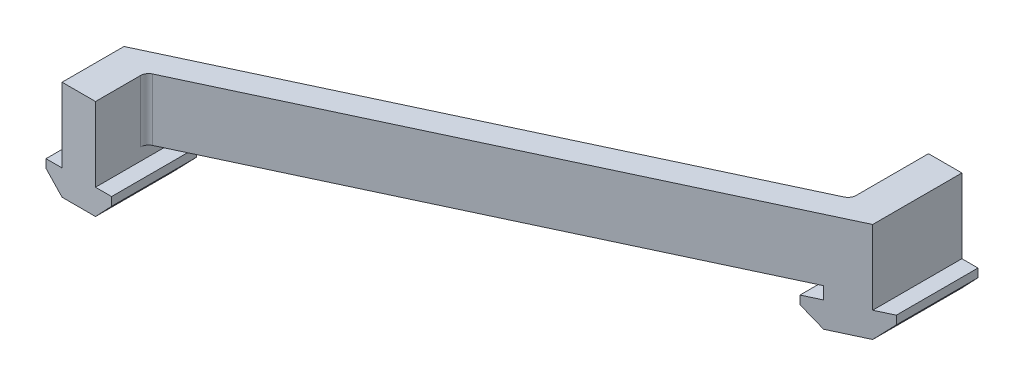
from build123d import *

# Parameters (mm, degrees)
BOSS_EXTRUDE1_DEPTH = 60
CUT_EXTRUDE2_DEPTH  = 25.152414984
BOSS_EXTRUDE2_DEPTH = 15
CUT_EXTRUDE3_DEPTH  = 25.152414984
BOSS_EXTRUDE3_DEPTH = 15
BOSS_EXTRUDE4_DEPTH = 15
CUT_EXTRUDE4_DEPTH  = 25.152414984
FILLET1_R           = 2


with BuildPart() as part:
    # Sketch1 → Boss-Extrude1 (new body)
    with BuildSketch(Plane.XY):
        Polygon((4.05, 18), (-124.05, 18), (-124.05, 0), (-115.95, 0), (-115.95, 3), (-4.05, 3), (-4.05, 0), (-7.95, 0), (-7.95, -2.04), (-4.048, -6.152414984), (4.048, -6.152414984), (7.95, -2.04), (7.95, 0), (4.05, 0), align=None)
    extrude(amount=BOSS_EXTRUDE1_DEPTH)

    # Sketch2 → Cut-Extrude2 (cut, through all)
    with BuildSketch(Plane(origin=(0, 18, 0), x_dir=(1, 0, 0), z_dir=(0, 1, 0))):
        Polygon((4.05, -60), (4.05, -6.625542325), (-109.904467136, -60), align=None)
        Polygon((-124.05, -60), (4.05, 0), (-124.05, 0), align=None)
        Polygon((11.122904285, -3.312706594), (4.05, -6.625542325), (4.05, -60), (-109.904467136, -60), (-126.032958173, -67.554328354), (-83.616740574, -158.112952928), (53.539121883, -93.871331168), align=None)
    extrude(amount=-CUT_EXTRUDE2_DEPTH, mode=Mode.SUBTRACT)

    # Sketch3 → Boss-Extrude2 (add, symmetric)
    with BuildSketch(Plane.XY.offset(60)):
        Polygon((-124.05, 18), (-124.05, 0), (-127.95, 0), (-127.95, -2.04), (-124.048, -6.152414984), (-115.952, -6.152414984), (-112.05, -2.04), (-112.05, 0), (-115.95, 0), (-115.95, 3), (-115.95, 18), align=None)
    extrude(amount=BOSS_EXTRUDE2_DEPTH, both=True)

    # Sketch2_4 → Cut-Extrude3 (cut, through all)
    with BuildSketch(Plane(origin=(0, 18, 0), x_dir=(1, 0, 0), z_dir=(0, 1, 0))):
        Polygon((4.05, 0), (-128.577931229, -62.12081088), (-170.994148827, 28.437813693), (-38.366217599, 90.558624573), align=None)
    extrude(amount=-CUT_EXTRUDE3_DEPTH, mode=Mode.SUBTRACT)

    # Sketch4 → Boss-Extrude3 (add)
    with BuildSketch(Plane(origin=(0, 18, 0), x_dir=(1, 0, 0), z_dir=(0, 1, 0))):
        Polygon((-109.904467136, -60), (-115.95, -62.831631318), (-115.95, -60), align=None)
    extrude(amount=-BOSS_EXTRUDE3_DEPTH)

    # Sketch6 → Boss-Extrude4 (add, symmetric)
    with BuildSketch(Plane(origin=(0, 0, 0), x_dir=(-1, 0, 0), z_dir=(0, 0, -1))):
        Polygon((-4.05, 0), (-7.95, 0), (-7.95, -2.04), (-4.05, -6.150307134), (4.048, -6.152414984), (7.95, -2.04), (7.95, 0), (4.05, 0), (4.05, 3), (4.05, 18), (-4.05, 18), align=None)
    extrude(amount=BOSS_EXTRUDE4_DEPTH, both=True)

    # Sketch7 → Cut-Extrude4 (cut, through all)
    with BuildSketch(Plane(origin=(0, 18, 0), x_dir=(1, 0, 0), z_dir=(0, 1, 0))):
        Polygon((-7.95, -12.246151224), (-7.95, -15), (7.95, -15), (7.95, -4.798844433), align=None)
    extrude(amount=-CUT_EXTRUDE4_DEPTH, mode=Mode.SUBTRACT)

    # Fillet1
    fillet1_edges = [part.edges().sort_by_distance(p)[0] for p in [
        (-115.95, 10.5, 62.831631318),
        (-4.05, 10.5, 3.793911007),
    ]]
    fillet(fillet1_edges, radius=FILLET1_R)


solid = part.part
